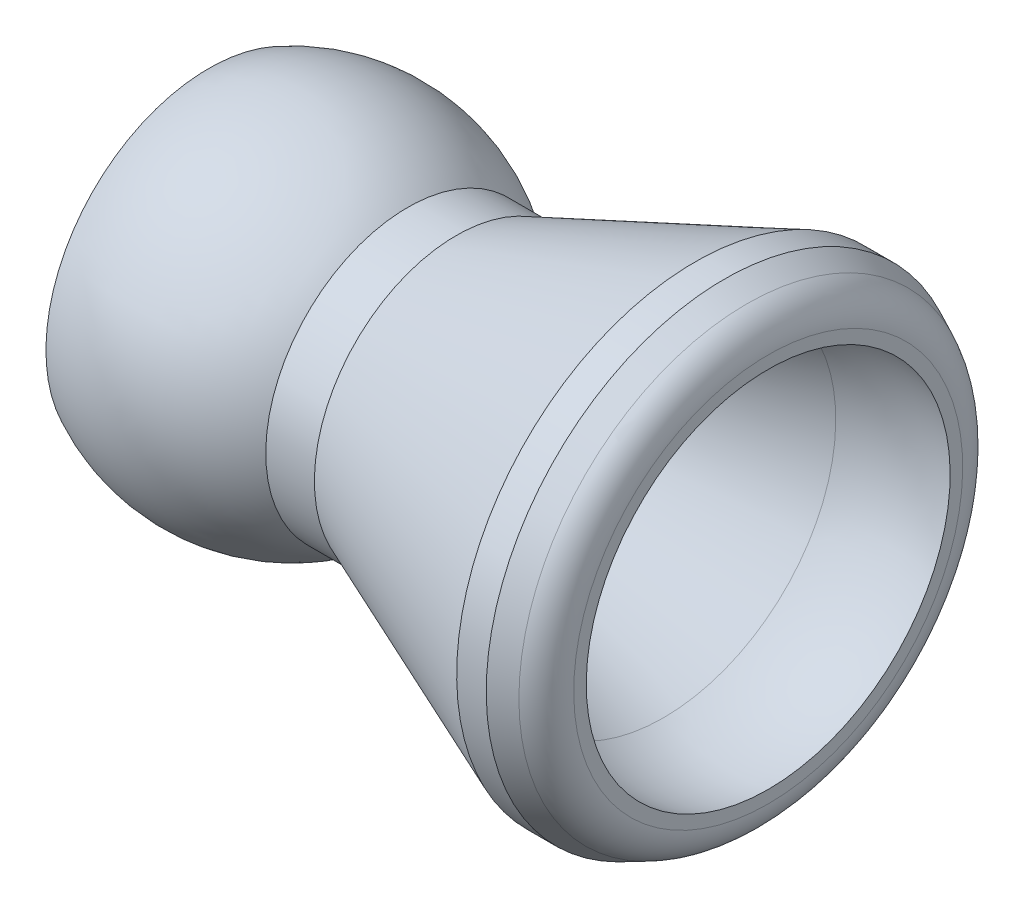
from build123d import *

# Parameters (mm, degrees)
FILLET1_R      = 1.27
CHAMFER1_SIZE  = 0.43942
CHAMFER1_SIZE2 = 0.177537204


with BuildPart() as part:
    # Sketch2 → Revolve1 (revolve)
    with BuildSketch(Plane.XY):
        with BuildLine():
            Line((-9.6139, 5.59308), (-9.6139, 4.5085))
            Line((-9.6139, 4.5085), (-5.482784752, 4.5085))
            Line((-5.482784752, 4.5085), (-3.173095, 3.175))
            Line((-3.173095, 3.175), (-0.77410359, 3.175))
            Line((-0.77410359, 3.175), (6.016717794, 5.918669934))
            ThreePointArc((6.016717794, 5.918669934), (7.790814141, 6.349535218), (9.6139, 6.252474944))
            Line((9.6139, 6.252474944), (9.6139, 7.492691343))
            Line((9.6139, 7.492691343), (8.1153, 8.1915))
            Line((8.1153, 8.1915), (7.099270393, 8.1915))
            Line((7.099270393, 8.1915), (-1.1049, 4.8768))
            Line((-1.1049, 4.8768), (-2.77622, 4.8768))
            ThreePointArc((-2.77622, 4.8768), (-6.088468301, 6.252474944), (-9.6139, 5.59308))
        make_face()
    revolve(axis=Axis((-152.4, 0, 0), (1, 0, 0)))

    # Fillet1
    fillet1_edges = [part.edges().sort_by_distance(p)[0] for p in [
        (9.6139, -7.492691343, 0),
    ]]
    fillet(fillet1_edges, radius=FILLET1_R)

    # Chamfer1
    chamfer1_edges = [part.edges().sort_by_distance(p)[0] for p in [
        (-9.6139, -4.5085, 0),
    ]]
    chamfer1_side = [part.faces().sort_by_distance(p)[0] for p in [
        (-7.548342376, -4.5085, 0),
    ]]
    chamfer(chamfer1_edges, length=CHAMFER1_SIZE, length2=CHAMFER1_SIZE2, reference=chamfer1_side[0])


solid = part.part
